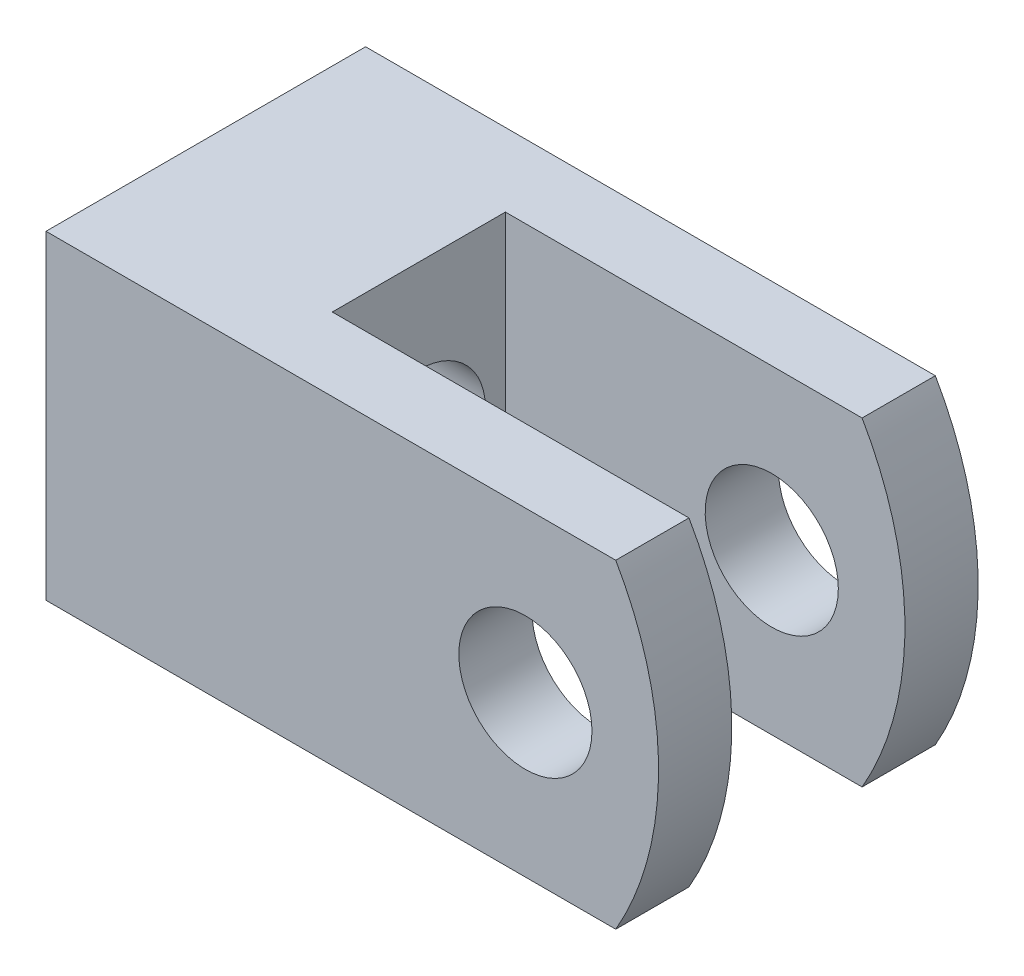
from build123d import *

# Parameters (mm, degrees)
BASE_EXTRUDE_DEPTH      = 6
SKETCH5_W               = 6.5
SKETCH5_H               = 12
CUT_EXTRUDE3_DEPTH      = 6
CUT_EXTRUDE3_DEPTH_BACK = 10
SKETCH7_R               = 2.5
CUT_EXTRUDE4_DEPTH      = 11
CHAMFER2_SIZE           = 0.2
SKETCH6_R               = 2.5
CUT_EXTRUDE5_DEPTH      = 7
CUT_EXTRUDE5_DEPTH_BACK = 7


with BuildPart() as part:
    # Sketch2 → Base-Extrude (new body, symmetric)
    with BuildSketch(Plane.XY):
        with BuildLine():
            Line((-18, 6), (3.392304845, 6))
            ThreePointArc((3.392304845, 6), (5, 0), (3.392304845, -6))
            Line((3.392304845, -6), (-18, -6))
            Line((-18, -6), (-18, 6))
        make_face()
    extrude(amount=BASE_EXTRUDE_DEPTH, both=True)

    # Sketch5 → Cut-Extrude3 (cut, two sides)
    with BuildSketch(Plane(origin=(0, 0, 0), x_dir=(0, 0, -1), z_dir=(1, 0, 0))) as cut_extrude3_sk:
        Rectangle(SKETCH5_W, SKETCH5_H)
    extrude(amount=CUT_EXTRUDE3_DEPTH, mode=Mode.SUBTRACT)
    extrude(cut_extrude3_sk.sketch, amount=-CUT_EXTRUDE3_DEPTH_BACK, mode=Mode.SUBTRACT)

    # Sketch7 → Cut-Extrude4 (cut)
    with BuildSketch(Plane.ZY.offset(18)):
        Circle(SKETCH7_R)
    extrude(amount=-CUT_EXTRUDE4_DEPTH, mode=Mode.SUBTRACT)

    # Chamfer2
    chamfer2_edges = [part.edges().sort_by_distance(p)[0] for p in [
        (-18, 0, -2.5),
    ]]
    chamfer(chamfer2_edges, length=CHAMFER2_SIZE)

    # Sketch6 → Cut-Extrude5 (cut, two sides)
    with BuildSketch(Plane.XY) as cut_extrude5_sk:
        Circle(SKETCH6_R)
    extrude(amount=CUT_EXTRUDE5_DEPTH, mode=Mode.SUBTRACT)
    extrude(cut_extrude5_sk.sketch, amount=-CUT_EXTRUDE5_DEPTH_BACK, mode=Mode.SUBTRACT)


solid = part.part
